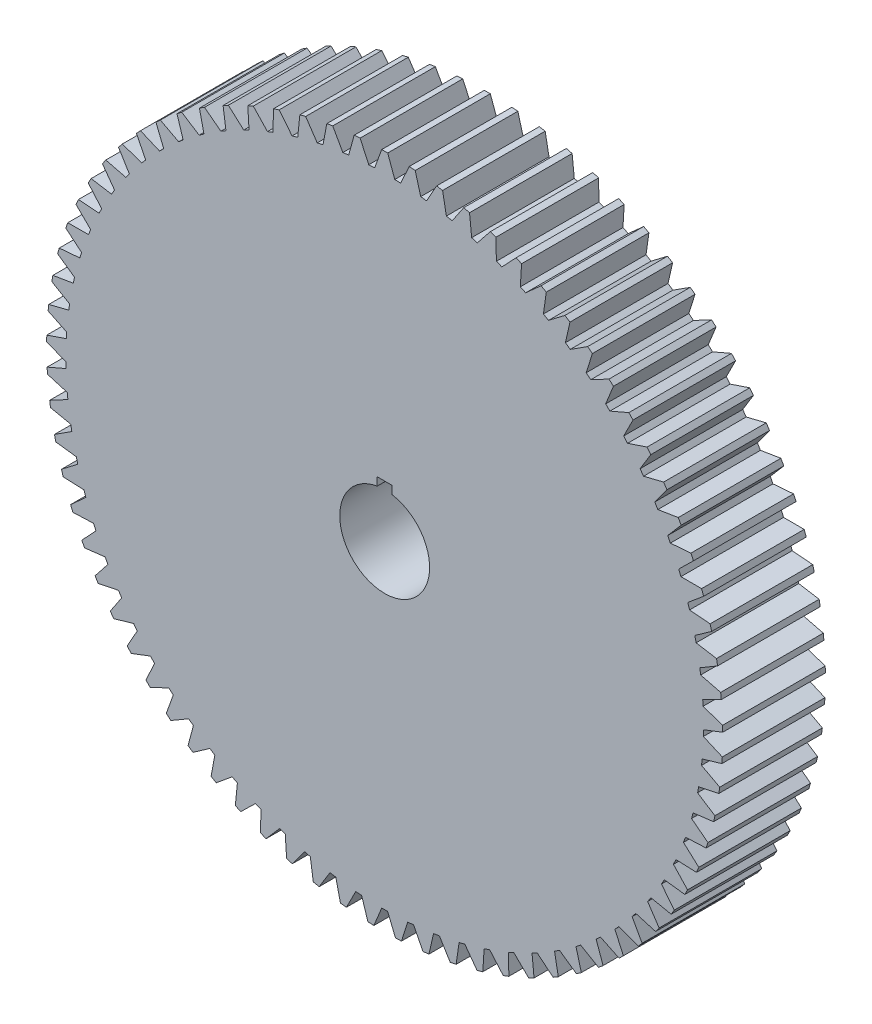
from build123d import *

# Parameters (mm, degrees)
BOSS_EXTRUDE1_DEPTH = 43.5102


with BuildPart() as part:
    # Sketch2 → Boss-Extrude1 (new body)
    with BuildSketch(Plane.XY):
        with BuildLine():
            Line((1.27, 143.32657345), (4.264662636, 135.098805479))
            ThreePointArc((4.264662636, 135.098805479), (5.513234102, 135.053614683), (6.76133452, 134.996884945))
            Line((6.76133452, 134.996884945), (10.416672135, 142.95318289))
            ThreePointArc((10.416672135, 142.95318289), (11.682904931, 142.855273929), (12.948220495, 142.74614931))
            Line((12.948220495, 142.74614931), (15.262279165, 134.301665752))
            ThreePointArc((15.262279165, 134.301665752), (16.503012644, 134.15485516), (17.74233611, 133.996582414))
            Line((17.74233611, 133.996582414), (22.034023036, 141.628462484))
            ThreePointArc((22.034023036, 141.628462484), (23.288062058, 141.427669579), (24.540272719, 141.215773098))
            Line((24.540272719, 141.215773098), (26.158327745, 132.610770599))
            ThreePointArc((26.158327745, 132.610770599), (27.382966359, 132.363317209), (28.605265381, 132.104554735))
            Line((28.605265381, 132.104554735), (33.504741149, 139.361228028))
            ThreePointArc((33.504741149, 139.361228028), (34.738240973, 139.058887422), (35.969013476, 138.745629215))
            Line((35.969013476, 138.745629215), (36.88029697, 130.037372646))
            ThreePointArc((36.88029697, 130.037372646), (38.080690951, 129.690923221), (39.277831329, 129.33339304))
            Line((39.277831329, 129.33339304), (44.752490738, 136.166567591))
            ThreePointArc((44.752490738, 136.166567591), (45.957242627, 135.764691312), (47.158386384, 135.352156062))
            Line((47.158386384, 135.352156062), (47.356833903, 126.598597433))
            ThreePointArc((47.356833903, 126.598597433), (48.524994828, 126.155457536), (49.689009791, 125.701538953))
            Line((49.689009791, 125.701538953), (55.702419884, 132.065741114))
            ThreePointArc((55.702419884, 132.065741114), (56.870406413, 131.567003581), (58.033928011, 131.057936641))
            Line((58.033928011, 131.057936641), (57.518218919, 122.317329441))
            ThreePointArc((57.518218919, 122.317329441), (58.64637287, 121.780448096), (59.769516091, 121.233161864))
            Line((59.769516091, 121.233161864), (66.281658616, 127.086038918))
            ThreePointArc((66.281658616, 127.086038918), (67.405107027, 126.493759148), (68.523263421, 125.891548274))
            Line((68.523263421, 125.891548274), (67.296829679, 117.222059803))
            ThreePointArc((67.296829679, 117.222059803), (68.377468977, 116.595009866), (69.452266123, 115.957998084))
            Line((69.452266123, 115.957998084), (76.419803846, 121.260600101))
            ThreePointArc((76.419803846, 121.260600101), (77.491237776, 120.578719618), (78.55658782, 119.887372425))
            Line((78.55658782, 119.887372425), (76.62759114, 111.346696697))
            ThreePointArc((76.62759114, 111.346696697), (77.653524309, 110.633651082), (78.672822782, 109.911152959))
            Line((78.672822782, 109.911152959), (86.04938789, 114.628191997))
            ThreePointArc((86.04938789, 114.628191997), (87.061677122, 113.861248604), (88.067131087, 113.085365892))
            Line((88.067131087, 113.085365892), (85.448408625, 104.730339695))
            ThreePointArc((85.448408625, 104.730339695), (86.412808248, 103.936043603), (87.369824786, 103.132867245))
            Line((87.369824786, 103.132867245), (95.106327454, 107.232952188))
            ThreePointArc((95.106327454, 107.232952188), (96.052735371, 106.386049765), (96.991602127, 105.530794907))
            Line((96.991602127, 105.530794907), (93.700581048, 97.417019562))
            ThreePointArc((93.700581048, 97.417019562), (94.597029206, 96.546758902), (95.48539502, 95.668249315))
            Line((95.48539502, 95.668249315), (103.530350101, 99.124094774))
            ThreePointArc((103.530350101, 99.124094774), (104.404578513, 98.202869318), (105.270610057, 97.273933893))
            Line((105.270610057, 97.273933893), (101.329191565, 89.455405237))
            ThreePointArc((101.329191565, 89.455405237), (102.151722542, 88.514971451), (102.965525705, 87.56697497))
            Line((102.965525705, 87.56697497), (111.265395349, 90.355582864))
            ThreePointArc((111.265395349, 90.355582864), (112.061626411, 89.366164978), (112.849059446, 88.369730899))
            Line((112.849059446, 88.369730899), (108.283473029, 80.898479949))
            ThreePointArc((108.283473029, 80.898479949), (109.026613018, 79.894131467), (109.760437805, 78.882956854))
            Line((109.760437805, 78.882956854), (118.259987748, 80.985769457))
            ThreePointArc((118.259987748, 80.985769457), (118.972922675, 79.934743554), (119.676516962, 78.877441925))
            Line((119.676516962, 78.877441925), (114.517145846, 71.803188624))
            ThreePointArc((114.517145846, 71.803188624), (115.175949373, 70.741609221), (115.8249123, 69.673985676))
            Line((115.8249123, 69.673985676), (124.467579441, 71.077009117))
            ThreePointArc((124.467579441, 71.077009117), (125.092473767, 69.971369601), (125.707547004, 68.860236588))
            Line((125.707547004, 68.860236588), (119.988725951, 62.230058925))
            ThreePointArc((119.988725951, 62.230058925), (120.558808788, 61.118313237), (121.118591113, 60.001345617))
            Line((121.118591113, 60.001345617), (129.846859928, 60.695243007))
            ThreePointArc((129.846859928, 60.695243007), (130.379555085, 59.542347727), (130.902014061, 58.384777739))
            Line((130.902014061, 58.384777739), (124.661800882, 52.242798452))
            ThreePointArc((124.661800882, 52.242798452), (125.13936922, 51.088284962), (125.606245686, 49.929406504))
            Line((125.606245686, 49.929406504), (134.362030985, 49.90956007))
            ThreePointArc((134.362030985, 49.90956007), (134.798981974, 48.717081352), (135.225349811, 47.520777827))
            Line((135.225349811, 47.520777827), (128.505272096, 41.907870774))
            ThreePointArc((128.505272096, 41.907870774), (128.887147797, 40.71827258), (129.258011418, 39.525195428))
            Line((129.258011418, 39.525195428), (137.983044895, 38.791737244))
            ThreePointArc((137.983044895, 38.791737244), (138.32134388, 37.567610839), (138.648783169, 36.340534978))
            Line((138.648783169, 36.340534978), (131.493561926, 31.29405313))
            ThreePointArc((131.493561926, 31.29405313), (131.777203671, 30.077286811), (132.049586409, 28.857950697))
            Line((132.049586409, 28.857950697), (140.685804406, 27.415761808))
            ThreePointArc((140.685804406, 27.415761808), (140.923200063, 26.168134075), (141.149531751, 24.918451865))
            Line((141.149531751, 24.918451865), (133.606783796, 20.471978727))
            ThreePointArc((133.606783796, 20.471978727), (133.790303995, 19.236141662), (133.962393189, 17.998661066))
            Line((133.962393189, 17.998661066), (142.4523231, 15.857338999))
            ThreePointArc((142.4523231, 15.857338999), (142.5872356, 14.594512695), (142.710953487, 13.330540566))
            Line((142.710953487, 13.330540566), (134.830874563, 9.513666682))
            ThreePointArc((134.830874563, 9.513666682), (134.913051921, 8.266983163), (134.983702346, 7.019593315))
            Line((134.983702346, 7.019593315), (143.270845088, 4.193388216))
            ThreePointArc((143.270845088, 4.193388216), (143.30237661, 2.923767241), (143.322657373, 1.653916719))
            Line((143.322657373, 1.653916719), (135.157688106, -1.507957245))
            ThreePointArc((135.157688106, -1.507957245), (135.137975745, -2.757190745), (135.106717233, -4.006188672))
            Line((135.106717233, -4.006188672), (143.135923239, -7.498468873))
            ThreePointArc((143.135923239, -7.498468873), (143.063863946, -8.766435401), (142.98057262, -10.033713671))
            Line((142.98057262, -10.033713671), (134.585049534, -12.519545965))
            ThreePointArc((134.585049534, -12.519545965), (134.463578636, -13.763016003), (134.330619209, -15.005310133))
            Line((134.330619209, -15.005310133), (142.048455436, -19.14042489))
            ThreePointArc((142.048455436, -19.14042489), (141.873284872, -20.398298862), (141.686975747, -21.654571352))
            Line((141.686975747, -21.654571352), (133.116769662, -23.447819172))
            ThreePointArc((133.116769662, -23.447819172), (132.894348597, -24.677250661), (132.660573076, -25.904573732))
            Line((132.660573076, -25.904573732), (140.0156786, -30.655004536))
            ThreePointArc((140.0156786, -30.655004536), (139.738562494, -31.89441501), (139.450475427, -33.131321433))
            Line((139.450475427, -33.131321433), (130.762619651, -34.220051011))
            ThreePointArc((130.762619651, -34.220051011), (130.440728594, -35.427262286), (130.107692718, -36.631446666))
            Line((130.107692718, -36.631446666), (137.051120523, -41.965580186))
            ThreePointArc((137.051120523, -41.965580186), (136.673903039, -43.178279088), (136.285955201, -44.387588037))
            Line((136.285955201, -44.387588037), (127.53826598, -44.764554057))
            ThreePointArc((127.53826598, -44.764554057), (127.119047063, -45.941511327), (126.68896713, -47.114543367))
            Line((126.68896713, -47.114543367), (133.174509851, -52.996881823))
            ThreePointArc((133.174509851, -52.996881823), (132.699701308, -54.174798843), (132.214474429, -55.348462565))
            Line((132.214474429, -55.348462565), (123.465166192, -55.011156381))
            ThreePointArc((123.465166192, -55.011156381), (122.951409247, -56.150027189), (122.427147369, -57.284100554))
            Line((122.427147369, -57.284100554), (128.411644788, -63.675497955))
            ThreePointArc((128.411644788, -63.675497955), (127.842404959, -64.810794249), (127.263128143, -65.941002207))
            Line((127.263128143, -65.941002207), (118.570426093, -64.891668536))
            ThreePointArc((118.570426093, -64.891668536), (117.965550088, -65.984873884), (117.350595141, -67.072441504))
            Line((117.350595141, -67.072441504), (122.794221415, -73.930364154))
            ThreePointArc((122.794221415, -73.930364154), (122.134338497, -75.015484513), (121.464866736, -76.094715359))
            Line((121.464866736, -76.094715359), (112.886619371, -74.340337342))
            ThreePointArc((112.886619371, -74.340337342), (112.194649657, -75.380602131), (111.493094063, -76.414426422))
            Line((111.493094063, -76.414426422), (116.359622758, -83.693235977))
            ThreePointArc((116.359622758, -83.693235977), (115.613488164, -84.720959104), (114.858276682, -85.742030735))
            Line((114.858276682, -85.742030735), (106.451570822, -83.29428347))
            ThreePointArc((106.451570822, -83.29428347), (105.677112342, -84.274684907), (104.89362484, -85.247885939))
            Line((104.89362484, -85.247885939), (109.15067001, -92.899143124))
            ThreePointArc((109.15067001, -92.899143124), (108.323249141, -93.86262969), (107.487323746, -94.818747043))
            Line((107.487323746, -94.818747043), (99.308104633, -91.693919883))
            ThreePointArc((99.308104633, -91.693919883), (98.456311281, -92.60793356), (97.59610585, -93.514034841))
            Line((97.59610585, -93.514034841), (101.215337562, -101.4868218))
            ThreePointArc((101.215337562, -101.4868218), (100.312136768, -102.379659962), (99.401060405, -103.264460233))
            Line((99.401060405, -103.264460233), (91.503759392, -99.483348388))
            ThreePointArc((91.503759392, -99.483348388), (90.580299712, -100.324891693), (89.649100877, -101.157863269))
            Line((89.649100877, -101.157863269), (92.606433742, -109.399122421))
            ThreePointArc((92.606433742, -109.399122421), (91.633463675, -110.215370488), (90.653299407, -111.022965477))
            Line((90.653299407, -111.022965477), (83.090471729, -106.610731623))
            ThreePointArc((83.090471729, -106.610731623), (82.101491193, -107.374204226), (81.105495929, -108.128502807))
            Line((81.105495929, -108.128502807), (83.381249384, -116.583389932))
            ThreePointArc((83.381249384, -116.583389932), (82.344984999, -117.317615908), (81.302255659, -118.042631204))
            Line((81.302255659, -118.042631204), (74.124230686, -113.028638028))
            ThreePointArc((74.124230686, -113.028638028), (73.076310796, -113.708959144), (72.022147288, -114.379564999))
            Line((72.022147288, -114.379564999), (73.601176568, -122.991814218))
            ThreePointArc((73.601176568, -122.991814218), (72.508514034, -123.63913195), (71.410158812, -124.276742696))
            Line((71.410158812, -124.276742696), (64.664705117, -118.694357496))
            ThreePointArc((64.664705117, -118.694357496), (63.564819608, -119.2869997), (62.459503138, -119.869450057))
            Line((62.459503138, -119.869450057), (63.331300066, -128.581748273))
            ThreePointArc((63.331300066, -128.581748273), (62.189510872, -129.137849968), (61.042839141, -129.68381297))
            Line((61.042839141, -129.68381297), (54.774846604, -123.570185598))
            ThreePointArc((54.774846604, -123.570185598), (53.630315032, -124.071204954), (52.481201301, -124.561623702))
            Line((52.481201301, -124.561623702), (52.63996421, -133.315992007))
            ThreePointArc((52.63996421, -133.315992007), (51.456646775, -133.777176901), (50.269289447, -134.227858865))
            Line((50.269289447, -134.227858865), (44.520470525, -127.623674502))
            ThreePointArc((44.520470525, -127.623674502), (43.338909559, -128.029736809), (42.153645728, -128.424860292))
            Line((42.153645728, -128.424860292), (41.598318078, -137.16303981))
            ThreePointArc((41.598318078, -137.16303981), (40.381347184, -137.526238793), (39.161205925, -137.878640504))
            Line((39.161205925, -137.878640504), (33.96981806, -130.827848909))
            ThreePointArc((33.96981806, -130.827848909), (32.759090792, -131.13625189), (31.545564597, -131.433450626))
            Line((31.545564597, -131.433450626), (30.279842002, -140.097290214))
            ThreePointArc((30.279842002, -140.097290214), (29.037316389, -140.360086256), (27.792511039, -140.61186254))
            Line((27.792511039, -140.61186254), (23.19310206, -133.161385567))
            ThreePointArc((23.19310206, -133.161385567), (21.961265681, -133.37007685), (20.727552938, -133.567373031))
            Line((20.727552938, -133.567373031), (18.759858573, -142.099216265))
            ThreePointArc((18.759858573, -142.099216265), (17.500047045, -142.259860503), (16.238861577, -142.40933583))
            Line((16.238861577, -142.40933583), (12.262039792, -134.608755173))
            ThreePointArc((12.262039792, -134.608755173), (11.017291971, -134.716345953), (9.771602835, -134.812426605))
            Line((9.771602835, -134.812426605), (7.115031381, -143.155495477))
            ThreePointArc((7.115031381, -143.155495477), (5.846317775, -143.212918849), (4.577145171, -143.259098486))
            Line((4.577145171, -143.259098486), (1.249375673, -135.160325723))
            ThreePointArc((1.249375673, -135.160325723), (0, -135.1661), (-1.249375673, -135.160325723))
            Line((-1.249375673, -135.160325723), (-4.577145171, -143.259098486))
            ThreePointArc((-4.577145171, -143.259098486), (-5.846317775, -143.212918849), (-7.115031381, -143.155495477))
            Line((-7.115031381, -143.155495477), (-9.771602835, -134.812426605))
            ThreePointArc((-9.771602835, -134.812426605), (-11.017291971, -134.716345953), (-12.262039792, -134.608755173))
            Line((-12.262039792, -134.608755173), (-16.238861577, -142.40933583))
            ThreePointArc((-16.238861577, -142.40933583), (-17.500047045, -142.259860503), (-18.759858573, -142.099216265))
            Line((-18.759858573, -142.099216265), (-20.727552938, -133.567373031))
            ThreePointArc((-20.727552938, -133.567373031), (-21.961265681, -133.37007685), (-23.19310206, -133.161385567))
            Line((-23.19310206, -133.161385567), (-27.792511039, -140.61186254))
            ThreePointArc((-27.792511039, -140.61186254), (-29.037316389, -140.360086256), (-30.279842002, -140.097290214))
            Line((-30.279842002, -140.097290214), (-31.545564597, -131.433450626))
            ThreePointArc((-31.545564597, -131.433450626), (-32.759090792, -131.13625189), (-33.96981806, -130.827848909))
            Line((-33.96981806, -130.827848909), (-39.161205925, -137.878640504))
            ThreePointArc((-39.161205925, -137.878640504), (-40.381347184, -137.526238793), (-41.598318078, -137.16303981))
            Line((-41.598318078, -137.16303981), (-42.153645728, -128.424860292))
            ThreePointArc((-42.153645728, -128.424860292), (-43.338909559, -128.029736809), (-44.520470525, -127.623674502))
            Line((-44.520470525, -127.623674502), (-50.269289447, -134.227858865))
            ThreePointArc((-50.269289447, -134.227858865), (-51.456646775, -133.777176901), (-52.63996421, -133.315992007))
            Line((-52.63996421, -133.315992007), (-52.481201301, -124.561623702))
            ThreePointArc((-52.481201301, -124.561623702), (-53.630315032, -124.071204954), (-54.774846604, -123.570185598))
            Line((-54.774846604, -123.570185598), (-61.042839141, -129.68381297))
            ThreePointArc((-61.042839141, -129.68381297), (-62.189510872, -129.137849968), (-63.331300066, -128.581748273))
            Line((-63.331300066, -128.581748273), (-62.459503138, -119.869450057))
            ThreePointArc((-62.459503138, -119.869450057), (-63.564819608, -119.2869997), (-64.664705117, -118.694357496))
            Line((-64.664705117, -118.694357496), (-71.410158812, -124.276742696))
            ThreePointArc((-71.410158812, -124.276742696), (-72.508514034, -123.63913195), (-73.601176568, -122.991814218))
            Line((-73.601176568, -122.991814218), (-72.022147288, -114.379564999))
            ThreePointArc((-72.022147288, -114.379564999), (-73.076310796, -113.708959144), (-74.124230686, -113.028638028))
            Line((-74.124230686, -113.028638028), (-81.302255659, -118.042631204))
            ThreePointArc((-81.302255659, -118.042631204), (-82.344984999, -117.317615908), (-83.381249384, -116.583389932))
            Line((-83.381249384, -116.583389932), (-81.105495929, -108.128502807))
            ThreePointArc((-81.105495929, -108.128502807), (-82.101491193, -107.374204226), (-83.090471729, -106.610731623))
            Line((-83.090471729, -106.610731623), (-90.653299407, -111.022965477))
            ThreePointArc((-90.653299407, -111.022965477), (-91.633463675, -110.215370488), (-92.606433742, -109.399122421))
            Line((-92.606433742, -109.399122421), (-89.649100877, -101.157863269))
            ThreePointArc((-89.649100877, -101.157863269), (-90.580299712, -100.324891693), (-91.503759392, -99.483348388))
            Line((-91.503759392, -99.483348388), (-99.401060405, -103.264460233))
            ThreePointArc((-99.401060405, -103.264460233), (-100.312136768, -102.379659962), (-101.215337562, -101.4868218))
            Line((-101.215337562, -101.4868218), (-97.59610585, -93.514034841))
            ThreePointArc((-97.59610585, -93.514034841), (-98.456311281, -92.60793356), (-99.308104633, -91.693919883))
            Line((-99.308104633, -91.693919883), (-107.487323746, -94.818747043))
            ThreePointArc((-107.487323746, -94.818747043), (-108.323249141, -93.86262969), (-109.15067001, -92.899143124))
            Line((-109.15067001, -92.899143124), (-104.89362484, -85.247885939))
            ThreePointArc((-104.89362484, -85.247885939), (-105.677112342, -84.274684907), (-106.451570822, -83.29428347))
            Line((-106.451570822, -83.29428347), (-114.858276682, -85.742030735))
            ThreePointArc((-114.858276682, -85.742030735), (-115.613488164, -84.720959104), (-116.359622758, -83.693235977))
            Line((-116.359622758, -83.693235977), (-111.493094063, -76.414426422))
            ThreePointArc((-111.493094063, -76.414426422), (-112.194649657, -75.380602131), (-112.886619371, -74.340337342))
            Line((-112.886619371, -74.340337342), (-121.464866736, -76.094715359))
            ThreePointArc((-121.464866736, -76.094715359), (-122.134338497, -75.015484513), (-122.794221415, -73.930364154))
            Line((-122.794221415, -73.930364154), (-117.350595141, -67.072441504))
            ThreePointArc((-117.350595141, -67.072441504), (-117.965550088, -65.984873884), (-118.570426093, -64.891668536))
            Line((-118.570426093, -64.891668536), (-127.263128143, -65.941002207))
            ThreePointArc((-127.263128143, -65.941002207), (-127.842404959, -64.810794249), (-128.411644788, -63.675497955))
            Line((-128.411644788, -63.675497955), (-122.427147369, -57.284100554))
            ThreePointArc((-122.427147369, -57.284100554), (-122.951409247, -56.150027189), (-123.465166192, -55.011156381))
            Line((-123.465166192, -55.011156381), (-132.214474429, -55.348462565))
            ThreePointArc((-132.214474429, -55.348462565), (-132.699701308, -54.174798843), (-133.174509851, -52.996881823))
            Line((-133.174509851, -52.996881823), (-126.68896713, -47.114543367))
            ThreePointArc((-126.68896713, -47.114543367), (-127.119047063, -45.941511327), (-127.53826598, -44.764554057))
            Line((-127.53826598, -44.764554057), (-136.285955201, -44.387588037))
            ThreePointArc((-136.285955201, -44.387588037), (-136.673903039, -43.178279088), (-137.051120523, -41.965580186))
            Line((-137.051120523, -41.965580186), (-130.107692718, -36.631446666))
            ThreePointArc((-130.107692718, -36.631446666), (-130.440728594, -35.427262286), (-130.762619651, -34.220051011))
            Line((-130.762619651, -34.220051011), (-139.450475427, -33.131321433))
            ThreePointArc((-139.450475427, -33.131321433), (-139.738562494, -31.89441501), (-140.0156786, -30.655004536))
            Line((-140.0156786, -30.655004536), (-132.660573076, -25.904573732))
            ThreePointArc((-132.660573076, -25.904573732), (-132.894348597, -24.677250661), (-133.116769662, -23.447819172))
            Line((-133.116769662, -23.447819172), (-141.686975747, -21.654571352))
            ThreePointArc((-141.686975747, -21.654571352), (-141.873284872, -20.398298862), (-142.048455436, -19.14042489))
            Line((-142.048455436, -19.14042489), (-134.330619209, -15.005310133))
            ThreePointArc((-134.330619209, -15.005310133), (-134.463578636, -13.763016003), (-134.585049534, -12.519545965))
            Line((-134.585049534, -12.519545965), (-142.98057262, -10.033713671))
            ThreePointArc((-142.98057262, -10.033713671), (-143.063863946, -8.766435401), (-143.135923239, -7.498468873))
            Line((-143.135923239, -7.498468873), (-135.106717233, -4.006188672))
            ThreePointArc((-135.106717233, -4.006188672), (-135.137975745, -2.757190745), (-135.157688106, -1.507957245))
            Line((-135.157688106, -1.507957245), (-143.322657373, 1.653916719))
            ThreePointArc((-143.322657373, 1.653916719), (-143.30237661, 2.923767241), (-143.270845088, 4.193388216))
            Line((-143.270845088, 4.193388216), (-134.983702346, 7.019593315))
            ThreePointArc((-134.983702346, 7.019593315), (-134.913051921, 8.266983163), (-134.830874563, 9.513666682))
            Line((-134.830874563, 9.513666682), (-142.710953487, 13.330540566))
            ThreePointArc((-142.710953487, 13.330540566), (-142.5872356, 14.594512695), (-142.4523231, 15.857338999))
            Line((-142.4523231, 15.857338999), (-133.962393189, 17.998661066))
            ThreePointArc((-133.962393189, 17.998661066), (-133.790303995, 19.236141662), (-133.606783796, 20.471978727))
            Line((-133.606783796, 20.471978727), (-141.149531751, 24.918451865))
            ThreePointArc((-141.149531751, 24.918451865), (-140.923200063, 26.168134075), (-140.685804406, 27.415761808))
            Line((-140.685804406, 27.415761808), (-132.049586409, 28.857950697))
            ThreePointArc((-132.049586409, 28.857950697), (-131.777203671, 30.077286811), (-131.493561926, 31.29405313))
            Line((-131.493561926, 31.29405313), (-138.648783169, 36.340534978))
            ThreePointArc((-138.648783169, 36.340534978), (-138.32134388, 37.567610839), (-137.983044895, 38.791737244))
            Line((-137.983044895, 38.791737244), (-129.258011418, 39.525195428))
            ThreePointArc((-129.258011418, 39.525195428), (-128.887147797, 40.71827258), (-128.505272096, 41.907870774))
            Line((-128.505272096, 41.907870774), (-135.225349811, 47.520777827))
            ThreePointArc((-135.225349811, 47.520777827), (-134.798981974, 48.717081352), (-134.362030985, 49.90956007))
            Line((-134.362030985, 49.90956007), (-125.606245686, 49.929406504))
            ThreePointArc((-125.606245686, 49.929406504), (-125.13936922, 51.088284962), (-124.661800882, 52.242798452))
            Line((-124.661800882, 52.242798452), (-130.902014061, 58.384777739))
            ThreePointArc((-130.902014061, 58.384777739), (-130.379555085, 59.542347727), (-129.846859928, 60.695243007))
            Line((-129.846859928, 60.695243007), (-121.118591113, 60.001345617))
            ThreePointArc((-121.118591113, 60.001345617), (-120.558808788, 61.118313237), (-119.988725951, 62.230058925))
            Line((-119.988725951, 62.230058925), (-125.707547004, 68.860236588))
            ThreePointArc((-125.707547004, 68.860236588), (-125.092473767, 69.971369601), (-124.467579441, 71.077009117))
            Line((-124.467579441, 71.077009117), (-115.8249123, 69.673985676))
            ThreePointArc((-115.8249123, 69.673985676), (-115.175949373, 70.741609221), (-114.517145846, 71.803188624))
            Line((-114.517145846, 71.803188624), (-119.676516962, 78.877441925))
            ThreePointArc((-119.676516962, 78.877441925), (-118.972922675, 79.934743554), (-118.259987748, 80.985769457))
            Line((-118.259987748, 80.985769457), (-109.760437805, 78.882956854))
            ThreePointArc((-109.760437805, 78.882956854), (-109.026613018, 79.894131467), (-108.283473029, 80.898479949))
            Line((-108.283473029, 80.898479949), (-112.849059446, 88.369730899))
            ThreePointArc((-112.849059446, 88.369730899), (-112.061626411, 89.366164978), (-111.265395349, 90.355582864))
            Line((-111.265395349, 90.355582864), (-102.965525705, 87.56697497))
            ThreePointArc((-102.965525705, 87.56697497), (-102.151722542, 88.514971451), (-101.329191565, 89.455405237))
            Line((-101.329191565, 89.455405237), (-105.270610057, 97.273933893))
            ThreePointArc((-105.270610057, 97.273933893), (-104.404578513, 98.202869318), (-103.530350101, 99.124094774))
            Line((-103.530350101, 99.124094774), (-95.48539502, 95.668249315))
            ThreePointArc((-95.48539502, 95.668249315), (-94.597029206, 96.546758902), (-93.700581048, 97.417019562))
            Line((-93.700581048, 97.417019562), (-96.991602127, 105.530794907))
            ThreePointArc((-96.991602127, 105.530794907), (-96.052735371, 106.386049765), (-95.106327454, 107.232952188))
            Line((-95.106327454, 107.232952188), (-87.369824786, 103.132867245))
            ThreePointArc((-87.369824786, 103.132867245), (-86.412808248, 103.936043603), (-85.448408625, 104.730339695))
            Line((-85.448408625, 104.730339695), (-88.067131087, 113.085365892))
            ThreePointArc((-88.067131087, 113.085365892), (-87.061677122, 113.861248604), (-86.04938789, 114.628191997))
            Line((-86.04938789, 114.628191997), (-78.672822782, 109.911152959))
            ThreePointArc((-78.672822782, 109.911152959), (-77.653524309, 110.633651082), (-76.62759114, 111.346696697))
            Line((-76.62759114, 111.346696697), (-78.55658782, 119.887372425))
            ThreePointArc((-78.55658782, 119.887372425), (-77.491237776, 120.578719618), (-76.419803846, 121.260600101))
            Line((-76.419803846, 121.260600101), (-69.452266123, 115.957998084))
            ThreePointArc((-69.452266123, 115.957998084), (-68.377468977, 116.595009866), (-67.296829679, 117.222059803))
            Line((-67.296829679, 117.222059803), (-68.523263421, 125.891548274))
            ThreePointArc((-68.523263421, 125.891548274), (-67.405107027, 126.493759148), (-66.281658616, 127.086038918))
            Line((-66.281658616, 127.086038918), (-59.769516091, 121.233161864))
            ThreePointArc((-59.769516091, 121.233161864), (-58.64637287, 121.780448096), (-57.518218919, 122.317329441))
            Line((-57.518218919, 122.317329441), (-58.033928011, 131.057936641))
            ThreePointArc((-58.033928011, 131.057936641), (-56.870406413, 131.567003581), (-55.702419884, 132.065741114))
            Line((-55.702419884, 132.065741114), (-49.689009791, 125.701538953))
            ThreePointArc((-49.689009791, 125.701538953), (-48.524994828, 126.155457536), (-47.356833903, 126.598597433))
            Line((-47.356833903, 126.598597433), (-47.158386384, 135.352156062))
            ThreePointArc((-47.158386384, 135.352156062), (-45.957242627, 135.764691312), (-44.752490738, 136.166567591))
            Line((-44.752490738, 136.166567591), (-39.277831329, 129.33339304))
            ThreePointArc((-39.277831329, 129.33339304), (-38.080690951, 129.690923221), (-36.88029697, 130.037372646))
            Line((-36.88029697, 130.037372646), (-35.969013476, 138.745629215))
            ThreePointArc((-35.969013476, 138.745629215), (-34.738240973, 139.058887422), (-33.504741149, 139.361228028))
            Line((-33.504741149, 139.361228028), (-28.605265381, 132.104554735))
            ThreePointArc((-28.605265381, 132.104554735), (-27.382966359, 132.363317209), (-26.158327745, 132.610770599))
            Line((-26.158327745, 132.610770599), (-24.540272719, 141.215773098))
            ThreePointArc((-24.540272719, 141.215773098), (-23.288062058, 141.427669579), (-22.034023036, 141.628462484))
            Line((-22.034023036, 141.628462484), (-17.74233611, 133.996582414))
            ThreePointArc((-17.74233611, 133.996582414), (-16.503012644, 134.15485516), (-15.262279165, 134.301665752))
            Line((-15.262279165, 134.301665752), (-12.948220495, 142.74614931))
            ThreePointArc((-12.948220495, 142.74614931), (-11.682904931, 142.855273929), (-10.416672135, 142.95318289))
            Line((-10.416672135, 142.95318289), (-6.76133452, 134.996884945))
            ThreePointArc((-6.76133452, 134.996884945), (-5.513234102, 135.053614683), (-4.264662636, 135.098805479))
            Line((-4.264662636, 135.098805479), (-1.27, 143.32657345))
            ThreePointArc((-1.27, 143.32657345), (0, 143.3322), (1.27, 143.32657345))
        make_face()
        with BuildLine():
            Line((0, 22.225), (-3.175, 22.225))
            Line((-3.175, 22.225), (-3.175, 18.783553311))
            ThreePointArc((-3.175, 18.783553311), (0, -19.05), (3.175, 18.783553311))
            Line((3.175, 18.783553311), (3.175, 22.225))
            Line((3.175, 22.225), (0, 22.225))
        make_face(mode=Mode.SUBTRACT)
    extrude(amount=BOSS_EXTRUDE1_DEPTH)


solid = part.part
